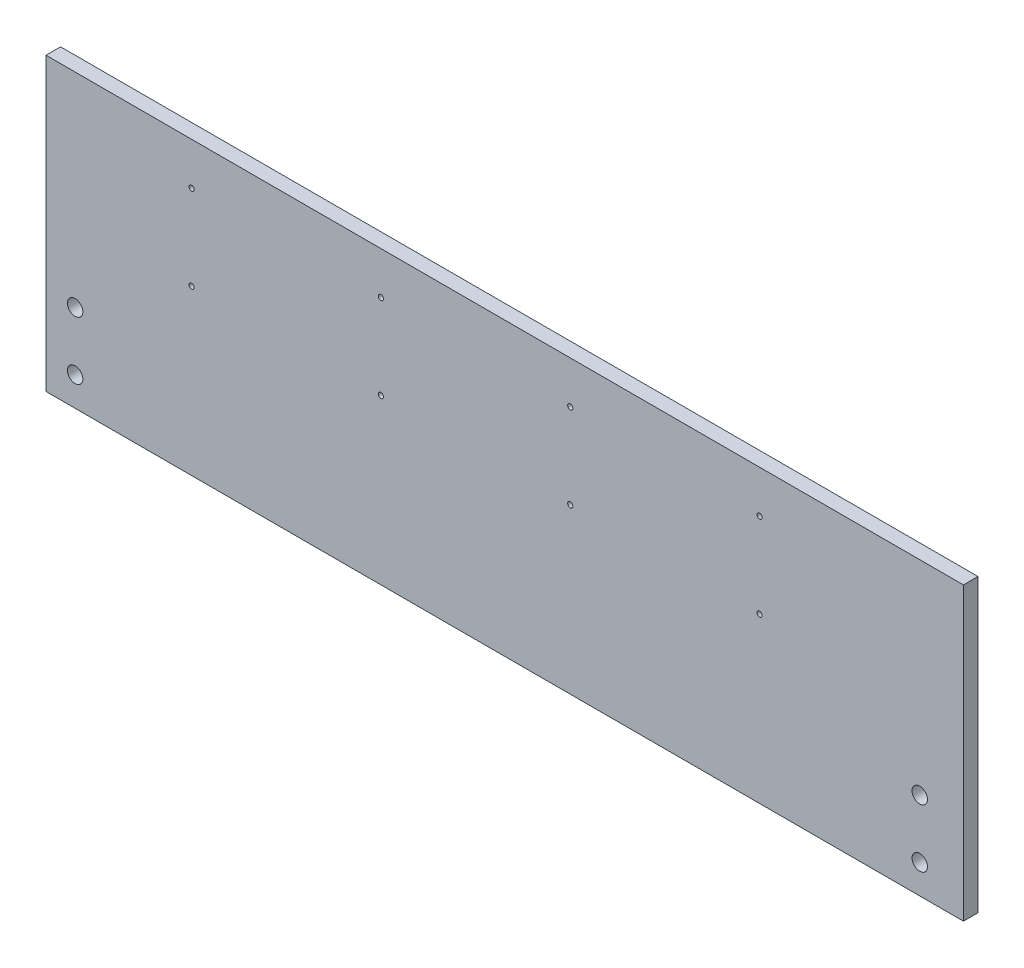
from build123d import *

# Parameters (mm, degrees)
SKETCH1_W             = 400.05
SKETCH1_H             = 127
BOSS_EXTRUDE1_DEPTH   = 6.35
SKETCH2_R             = 3.3655
CUT_EXTRUDE1_DEPTH    = 7.35
F_4_40_TAPPED_HOLE1_D = 2.2606


with BuildPart() as part:
    # Sketch1 → Boss-Extrude1 (new body)
    with BuildSketch(Plane.XY):
        Rectangle(SKETCH1_W, SKETCH1_H)
    extrude(amount=BOSS_EXTRUDE1_DEPTH)

    # Sketch2 → Cut-Extrude1 (cut, through all)
    with BuildSketch(Plane(origin=(0, 0, 0), x_dir=(-1, 0, 0), z_dir=(0, 0, -1))):
        with Locations((-180.975, -50.8)):
            Circle(SKETCH2_R)
        with Locations((-180.975, -25.4)):
            Circle(SKETCH2_R)
        with Locations((187.325, -50.8)):
            Circle(SKETCH2_R)
        with Locations((187.325, -25.4)):
            Circle(SKETCH2_R)
    extrude(amount=-CUT_EXTRUDE1_DEPTH, mode=Mode.SUBTRACT)

    # #4-40 Tapped Hole1 (through all)
    with Locations(Plane.XY.offset(6.35)):
        with Locations((-136.525, 45.025), (-136.525, 8.025), (-53.975, 45.025), (-53.975, 8.025), (28.575, 45.025), (28.575, 8.025), (111.125, 45.025), (111.125, 8.025)):
            Hole(F_4_40_TAPPED_HOLE1_D / 2)


solid = part.part
